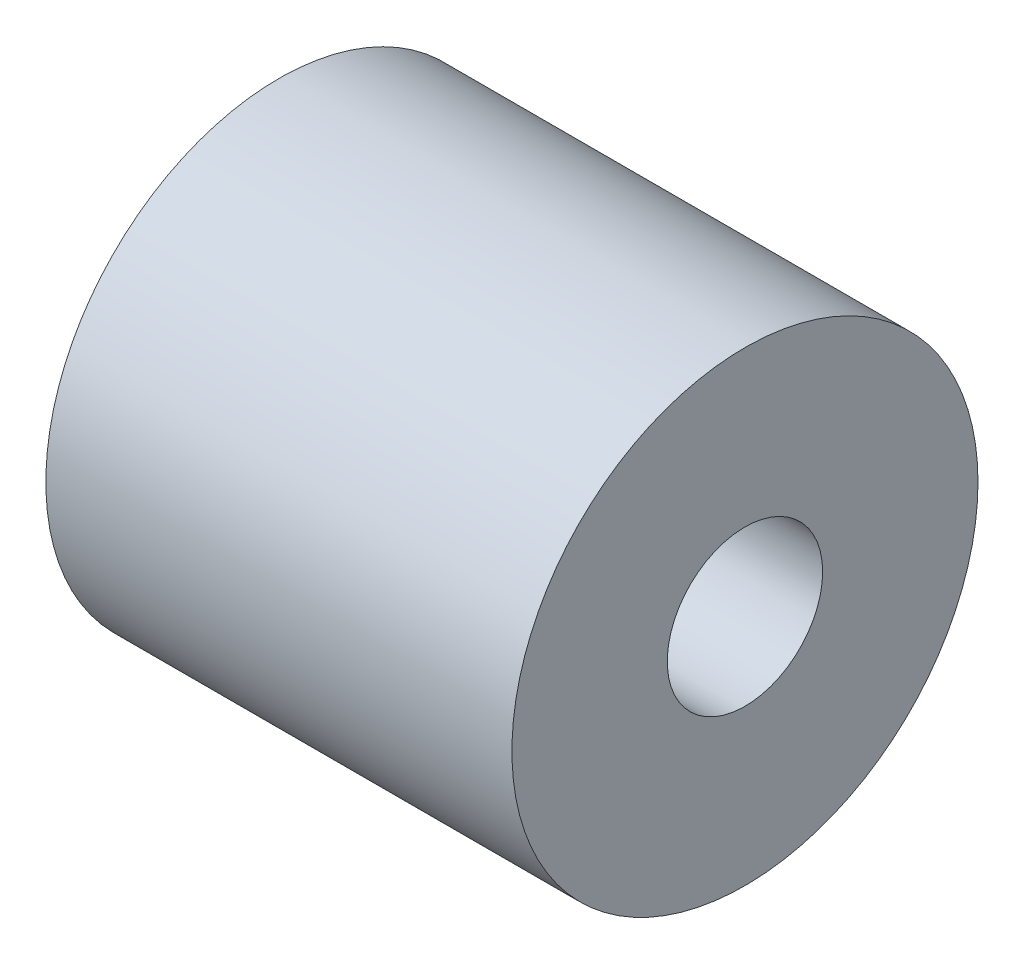
from build123d import *


with BuildPart() as part:
    # Эскиз1 → Повернуть1 (revolve)
    with BuildSketch(Plane.XY):
        Polygon((0, 3.175), (0, 5), (15, 5), (15, 15), (-15, 15), (-15, 3.175), align=None)
    revolve(axis=Axis((-15, 0, 0), (1, 0, 0)))


solid = part.part
